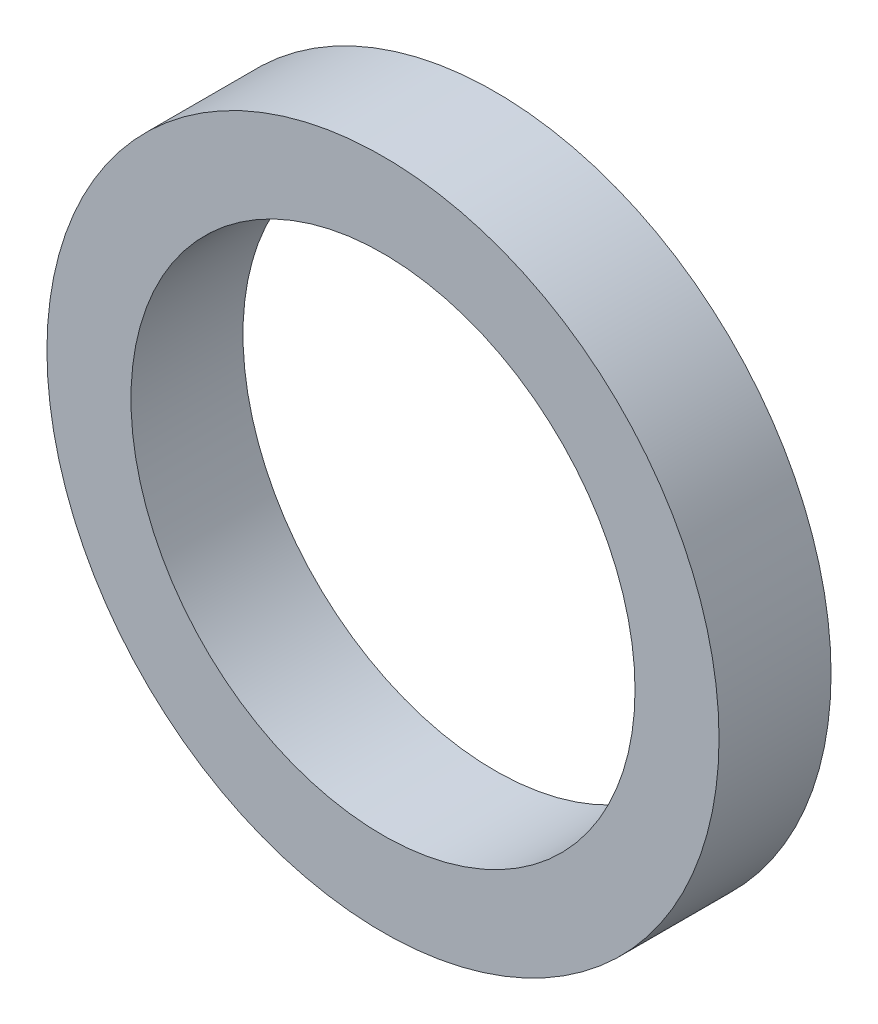
from build123d import *

# Parameters (mm, degrees)
SKETCH_1_R      = 3
SKETCH_1_R_2    = 2.25
EXTRUDE_1_DEPTH = 1


with BuildPart() as part:
    # 草图1 → 凸台-拉伸1 (new body)
    with BuildSketch(Plane.XY):
        Circle(SKETCH_1_R)
        Circle(SKETCH_1_R_2, mode=Mode.SUBTRACT)
    extrude(amount=EXTRUDE_1_DEPTH)


solid = part.part
